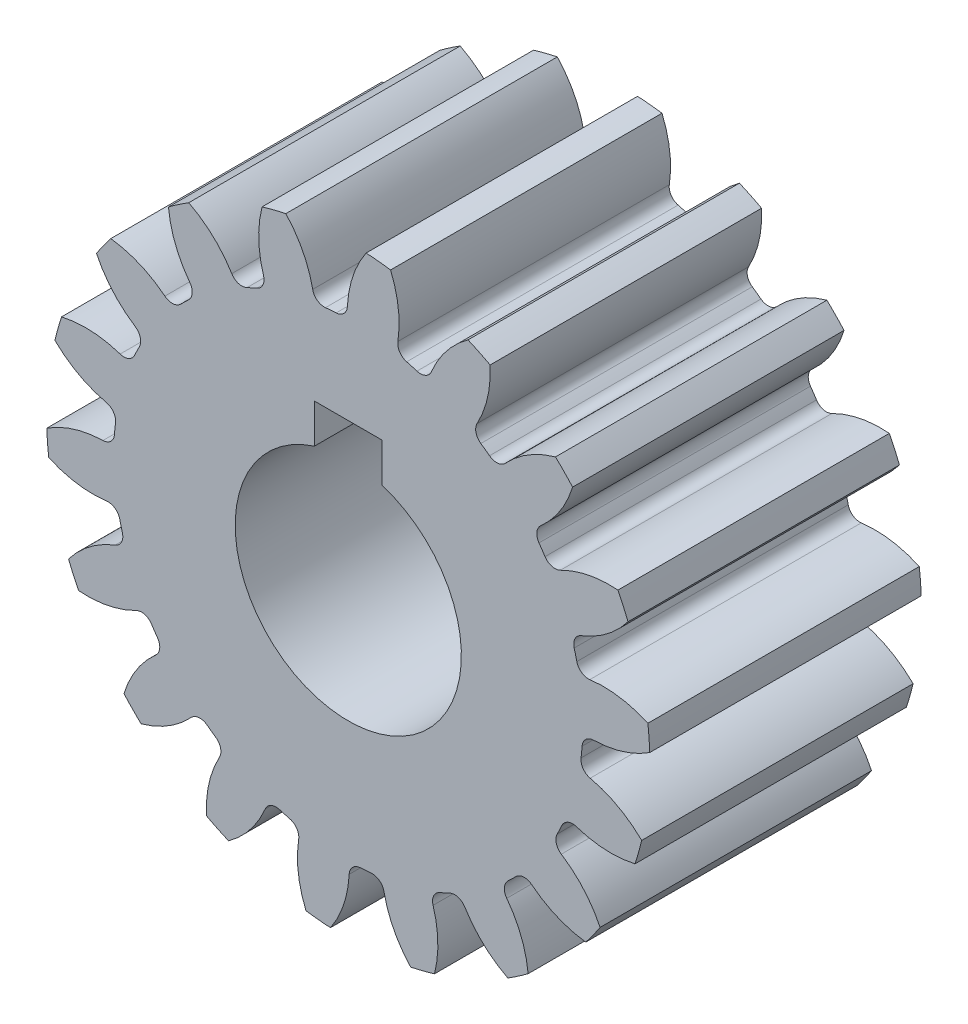
from build123d import *

# Parameters (mm, degrees)
SKETCH3_R          = 21.166666667
GEARBODY_DEPTH     = 19.05
TOOTHCUT_DEPTH     = 20.05
CIRPATTERN1_COUNT  = 18
BOREDIA_R          = 7.9375
BORE_DEPTH         = 12700
CUT_EXTRUDE1_DEPTH = 20.05


with BuildPart() as part:
    # Sketch3 → gearBody (new body)
    with BuildSketch(Plane.XY):
        Circle(SKETCH3_R)
    extrude(amount=GEARBODY_DEPTH)

    # Sketch2 → toothCut (cut, through all)
    with BuildSketch(Plane.XY):
        with BuildLine():
            ThreePointArc((16.335269031, -2.015998593), (16.377127438, -1.641633799), (16.410407448, -1.266409111))
            ThreePointArc((16.410407448, -1.266409111), (16.667413848, -0.726792607), (17.219915542, -0.498801072))
            ThreePointArc((17.219915542, -0.498801072), (20.650307967, 0.417339666), (23.283949955, 2.798691365))
            ThreePointArc((23.283949955, 2.798691365), (23.334606399, -2.339047473), (22.265196368, -7.364511495))
            ThreePointArc((22.265196368, -7.364511495), (20.156614608, -4.507802025), (16.976312891, -2.929009122))
            ThreePointArc((16.976312891, -2.929009122), (16.480056536, -2.595890687), (16.335269031, -2.015998593))
        make_face()
    toothcut = extrude(amount=TOOTHCUT_DEPTH, mode=Mode.SUBTRACT)

    # CirPattern1: toothCut ×18 about axis
    cirpattern1_axis = Axis((0, 0, 0), (0, 0, 1))
    for i in range(1, CIRPATTERN1_COUNT):
        add(toothcut.rotate(cirpattern1_axis, i * 360 / CIRPATTERN1_COUNT), mode=Mode.SUBTRACT)

    # boreDia → bore (cut, symmetric)
    with BuildSketch(Plane.XY):
        Circle(BOREDIA_R)
    extrude(amount=BORE_DEPTH, both=True, mode=Mode.SUBTRACT)

    # Sketch4 → Cut-Extrude1 (cut, through all)
    with BuildSketch(Plane(origin=(0, 0, 0), x_dir=(-1, 0, 0), z_dir=(0, 0, -1))):
        with BuildLine():
            Line((0, 10.31875), (2.38125, 10.31875))
            Line((2.38125, 10.31875), (2.38125, 7.571892411))
            ThreePointArc((2.38125, 7.571892411), (0, 7.9375), (-2.38125, 7.571892411))
            Line((-2.38125, 7.571892411), (-2.38125, 10.31875))
            Line((-2.38125, 10.31875), (0, 10.31875))
        make_face()
    extrude(amount=-CUT_EXTRUDE1_DEPTH, mode=Mode.SUBTRACT)


solid = part.part
